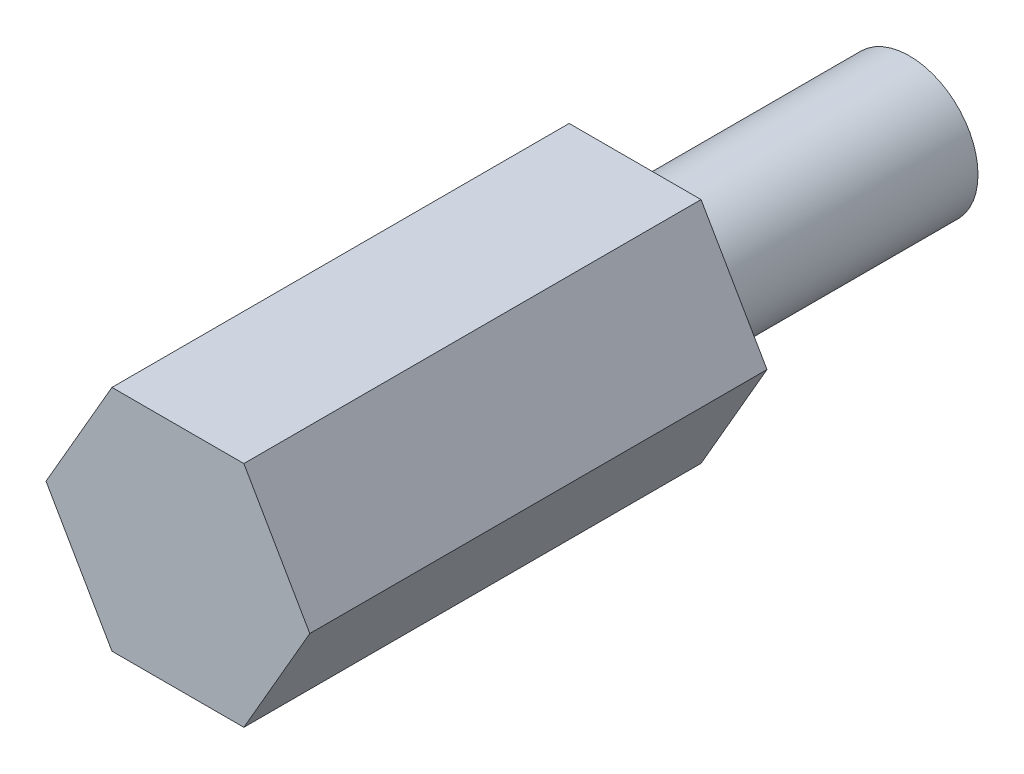
from build123d import *

# Parameters (mm, degrees)
SALIENTE_EXTRUIR1_DEPTH = 10
CORTE_EXTERIOR_R        = 1.5
SALIENTE_EXTRUIR2_DEPTH = 6


with BuildPart() as part:
    # Sketch 0 → Saliente-Extruir1 (new body)
    with BuildSketch(Plane.XY):
        Polygon((35.350833333, 22.415149957), (32.465833333, 22.415149957), (31.023333333, 19.916666667), (32.465833333, 17.418183377), (35.350833333, 17.418183377), (36.793333333, 19.916666667), align=None)
    extrude(amount=SALIENTE_EXTRUIR1_DEPTH)

    # Corte exterior → Saliente-Extruir2 (add)
    with BuildSketch(Plane.XY):
        with Locations((33.908333333, 19.916666667)):
            Circle(CORTE_EXTERIOR_R)
    extrude(amount=-SALIENTE_EXTRUIR2_DEPTH)


solid = part.part
